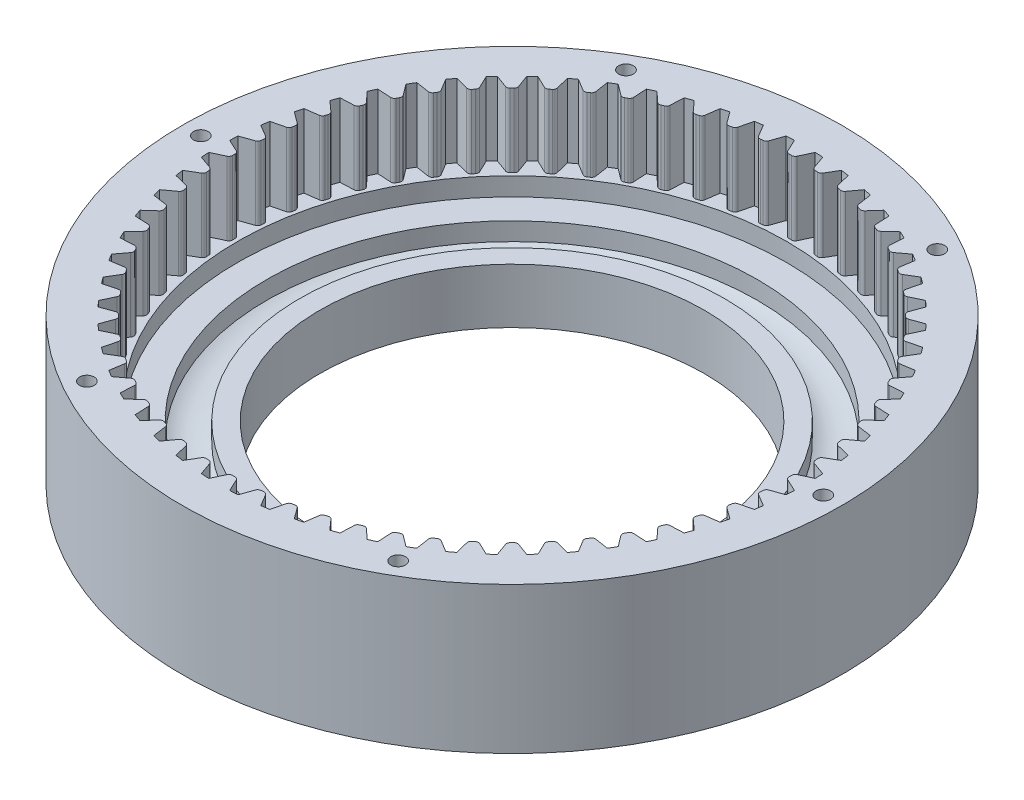
from build123d import *

# Parameters (mm, degrees)
BOSS_EXTRUDE1_DEPTH = 20
CIRPATTERN1_COUNT   = 64
SKETCH3_R           = 2
CUT_EXTRUDE1_DEPTH  = 15
CIRPATTERN2_COUNT   = 6
SKETCH4_R           = 4
CUT_EXTRUDE2_DEPTH  = 12
CIRPATTERN3_COUNT   = 4


with BuildPart() as part:
    # Sketch1 → Revolve1 (revolve)
    with BuildSketch(Plane.XY):
        with BuildLine():
            Line((-90, 0), (-90, 40))
            Line((-90, 40), (-80, 40))
            Line((-80, 40), (-80, 20))
            Line((-80, 20), (-75, 20))
            Line((-75, 20), (-75, 15))
            Line((-75, 15), (-67, 15))
            Line((-67, 15), (-67, 10.06971445))
            ThreePointArc((-67, 10.06971445), (-62.5, 9), (-58, 10.06971445))
            Line((-58, 10.06971445), (-58, 15))
            Line((-58, 15), (-52.5, 15))
            Line((-52.5, 15), (-52.5, 0))
            Line((-52.5, 0), (-90, 0))
        make_face()
    revolve(axis=Axis((0, 0, 0), (0, 1, 0)))

    # Sketch2 → Boss-Extrude1 (add)
    with BuildSketch(Plane(origin=(0, 20, 0), x_dir=(1, 0, 0), z_dir=(0, 1, 0))):
        with BuildLine():
            Line((-79.949514104, 2.841688673), (-76.577381738, 1.269237526))
            ThreePointArc((-76.577381738, 1.269237526), (-76.156608554, 0.900229348), (-76, 0.362929739))
            Line((-76, 0.362929739), (-76, -0.362929739))
            ThreePointArc((-76, -0.362929739), (-76.156608554, -0.900229348), (-76.577381738, -1.269237526))
            Line((-76.577381738, -1.269237526), (-79.949514104, -2.841688673))
            ThreePointArc((-79.949514104, -2.841688673), (-80, 0), (-79.949514104, 2.841688673))
        make_face()
    boss_extrude1 = extrude(amount=BOSS_EXTRUDE1_DEPTH)

    # CirPattern1: Boss-Extrude1 ×64 about axis
    cirpattern1_axis = Axis((0, 0, 0), (0, 1, 0))
    for i in range(1, CIRPATTERN1_COUNT):
        add(boss_extrude1.rotate(cirpattern1_axis, i * 360 / CIRPATTERN1_COUNT))

    # Sketch3 → Cut-Extrude1 (cut)
    with BuildSketch(Plane(origin=(0, 40, 0), x_dir=(1, 0, 0), z_dir=(0, 1, 0))):
        with Locations((-85, 0)):
            Circle(SKETCH3_R)
    cut_extrude1 = extrude(amount=-CUT_EXTRUDE1_DEPTH, mode=Mode.SUBTRACT)

    # CirPattern2: Cut-Extrude1 ×6 about axis
    cirpattern2_axis = Axis((0, 0, 0), (0, 1, 0))
    for i in range(1, CIRPATTERN2_COUNT):
        add(cut_extrude1.rotate(cirpattern2_axis, i * 360 / CIRPATTERN2_COUNT), mode=Mode.SUBTRACT)

    # Sketch4 → Cut-Extrude2 (cut)
    with BuildSketch(Plane(origin=(0, 0, 0), x_dir=(-1, 0, 0), z_dir=(0, -1, 0))):
        with Locations((78, 0)):
            Circle(SKETCH4_R)
    cut_extrude2 = extrude(amount=-CUT_EXTRUDE2_DEPTH, mode=Mode.SUBTRACT)

    # CirPattern3: Cut-Extrude2 ×4 about axis
    cirpattern3_axis = Axis((0, 0, 0), (0, 1, 0))
    for i in range(1, CIRPATTERN3_COUNT):
        add(cut_extrude2.rotate(cirpattern3_axis, i * 360 / CIRPATTERN3_COUNT), mode=Mode.SUBTRACT)


solid = part.part
